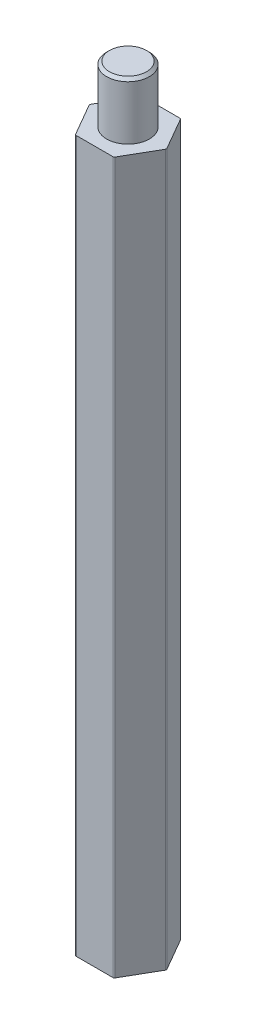
from build123d import *

# Parameters (mm, degrees)
EXTRUDE_1_DEPTH     = 50
SKETCH_2_R          = 1.5
EXTRUDE_2_DEPTH     = 4
SKETCH_3_R          = 1.5
CUT_EXTRUDE_1_DEPTH = 4
CHAMFER_1_SIZE      = 0.2
FILLET_1_R          = 0.1


with BuildPart() as part:
    # 草图1 → 凸台-拉伸1 (new body)
    with BuildSketch(Plane(origin=(0, 0, 0), x_dir=(1, 0, 0), z_dir=(0, 1, 0))):
        Polygon((2.713546265, 0), (1.356773133, 2.35), (-1.356773133, 2.35), (-2.713546265, 0), (-1.356773133, -2.35), (1.356773133, -2.35), align=None)
    extrude(amount=EXTRUDE_1_DEPTH)

    # 草图2 → 凸台-拉伸2 (add)
    with BuildSketch(Plane(origin=(0, 50, 0), x_dir=(1, 0, 0), z_dir=(0, 1, 0))):
        Circle(SKETCH_2_R)
    extrude(amount=EXTRUDE_2_DEPTH)

    # 草图3 → 切除-拉伸1 (cut)
    with BuildSketch(Plane.XZ):
        Circle(SKETCH_3_R)
    extrude(amount=-CUT_EXTRUDE_1_DEPTH, mode=Mode.SUBTRACT)

    # 倒角1
    chamfer_1_edges = [part.edges().sort_by_distance(p)[0] for p in [
        (-1.5, 4, 0),
        (-1.5, 54, 0),
    ]]
    chamfer(chamfer_1_edges, length=CHAMFER_1_SIZE)

    # 圆角1
    fillet_1_edges = [part.edges().sort_by_distance(p)[0] for p in [
        (2.713546265, 25, 0),
        (1.356773133, 25, -2.35),
        (1.356773133, 25, 2.35),
        (-1.356773133, 25, -2.35),
        (-1.356773133, 25, 2.35),
        (-2.713546265, 25, 0),
    ]]
    fillet(fillet_1_edges, radius=FILLET_1_R)


solid = part.part
